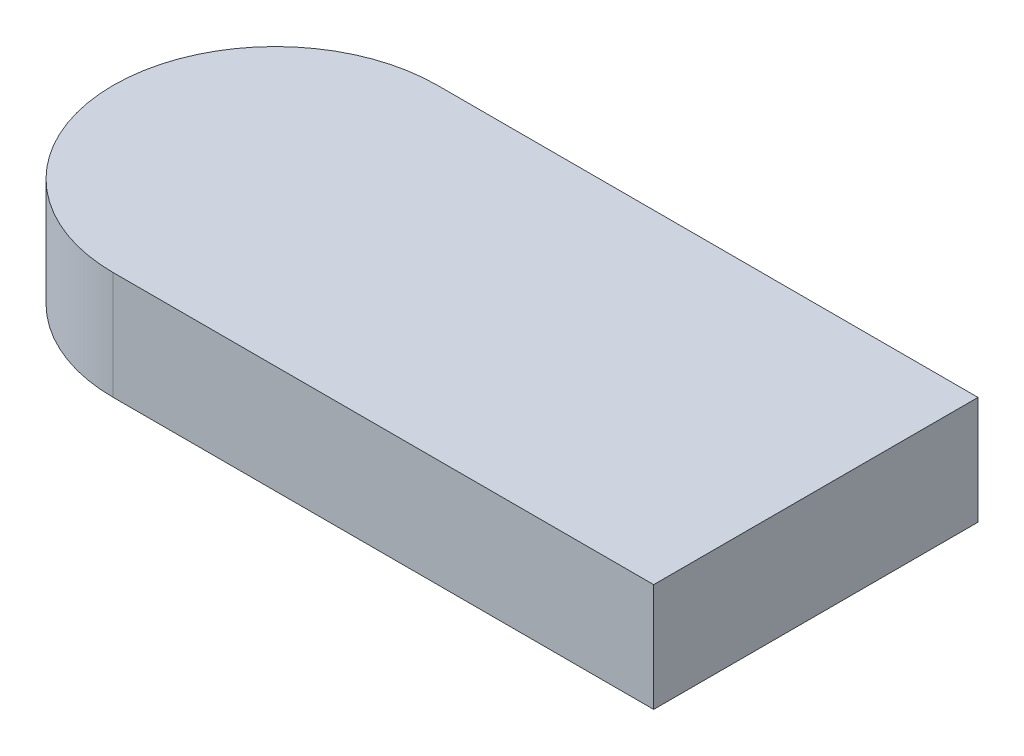
from build123d import *

# Parameters (mm, degrees)
BOSS_EXTRUDE1_DEPTH = 15


with BuildPart() as part:
    # Sketch1 → Boss-Extrude1 (new body, symmetric)
    with BuildSketch(Plane(origin=(0, 0, 0), x_dir=(1, 0, 0), z_dir=(0, 1, 0))):
        with BuildLine():
            Line((-75, 45), (75, 45))
            Line((75, 45), (75, -45))
            Line((75, -45), (-75, -45))
            ThreePointArc((-75, -45), (-120, 0), (-75, 45))
        make_face()
    extrude(amount=BOSS_EXTRUDE1_DEPTH, both=True)


solid = part.part
